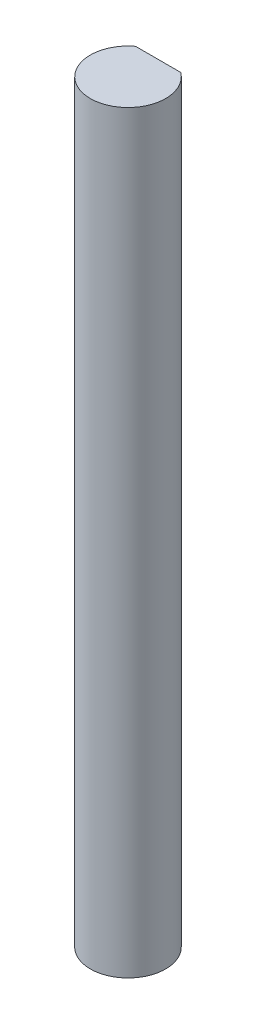
from build123d import *

# Parameters (mm, degrees)
BOSS_EXTRUDE1_DEPTH = 63.5


with BuildPart() as part:
    # Sketch1 → Boss-Extrude1 (new body)
    with BuildSketch(Plane(origin=(0, 0, 0), x_dir=(1, 0, 0), z_dir=(0, 1, 0))):
        with BuildLine():
            Line((-1.905, 2.54), (1.905, 2.54))
            ThreePointArc((1.905, 2.54), (0, -3.175), (-1.905, 2.54))
        make_face()
    extrude(amount=BOSS_EXTRUDE1_DEPTH)


solid = part.part
